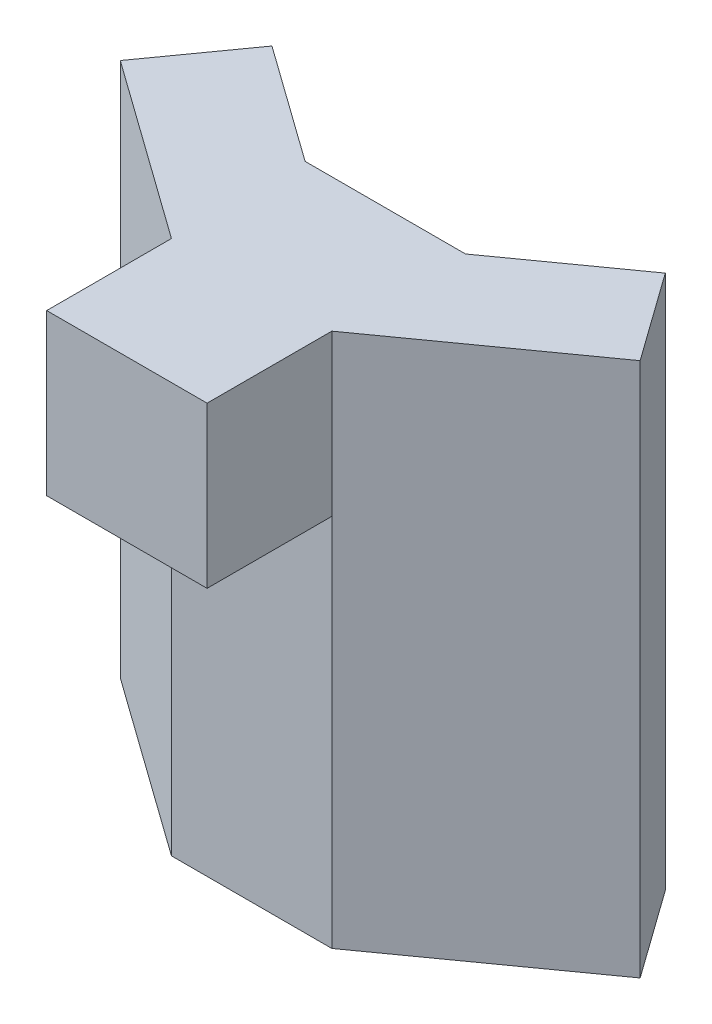
from build123d import *

# Parameters (mm, degrees)
BOSS_EXTRUDE1_DEPTH = 300
SKETCH3_W           = 90
SKETCH3_H           = 90
BOSS_EXTRUDE2_DEPTH = 70


with BuildPart() as part:
    # Sketch2 → Boss-Extrude1 (new body)
    with BuildSketch(Plane(origin=(0, 0, 0), x_dir=(1, 0, 0), z_dir=(0, 1, 0))):
        Polygon((0, 0), (0, 75), (45, 75), (110.363656587, 121.756282785), (145.853333333, 72.142949451), (45, 0), align=None)
    boss_extrude1 = extrude(amount=BOSS_EXTRUDE1_DEPTH)

    # Mirror1: Boss-Extrude1 across plane
    add(boss_extrude1.mirror(Plane(origin=(0, 0, 0), x_dir=(0, 0, 1), z_dir=(1, 0, 0))))

    # Sketch3 → Boss-Extrude2 (add)
    with BuildSketch(Plane.XY):
        with Locations((0, 255)):
            Rectangle(SKETCH3_W, SKETCH3_H)
    extrude(amount=BOSS_EXTRUDE2_DEPTH)


solid = part.part
